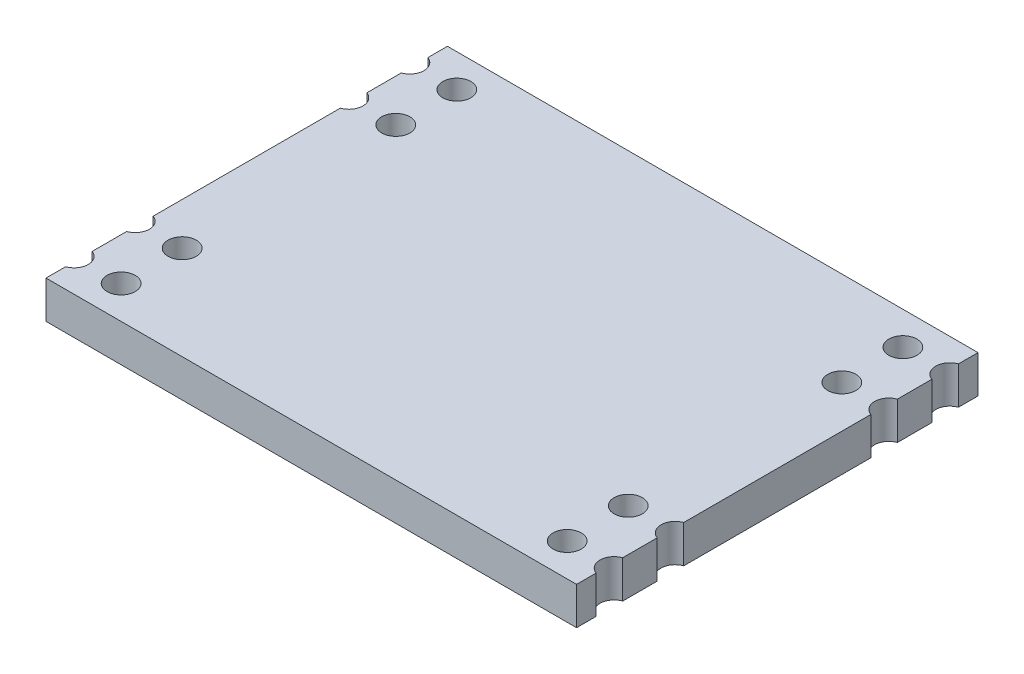
from build123d import *

# Parameters (mm, degrees)
SKETCH1_W                       = 22.6
SKETCH1_H                       = 17.1
MAIN_BODY_DEPTH                 = 1.6
SKETCH2_R                       = 0.6
SOLDERED_CONNECTION_HOLES_DEPTH = 2.6
LPATTERN1_COUNT                 = 2
LPATTERN1_PITCH                 = 2
MIRROR1_COPY_1_SKETCH_R         = 0.6
MIRROR1_COPY_1_DEPTH            = 2.6
MIRROR2_COPY_1_SKETCH_R         = 0.6
MIRROR2_COPY_1_DEPTH            = 2.6
MIRROR2_COPY_2_SKETCH_R         = 0.6
MIRROR2_COPY_2_DEPTH            = 2.6
MIRROR2_COPY_3_SKETCH_R         = 0.6
MIRROR2_COPY_3_DEPTH            = 2.6


with BuildPart() as part:
    # Sketch1 → MAIN BODY (new body)
    with BuildSketch(Plane(origin=(0, 0, 0), x_dir=(1, 0, 0), z_dir=(0, 1, 0))):
        Rectangle(SKETCH1_W, SKETCH1_H)
    extrude(amount=MAIN_BODY_DEPTH)

    # Sketch2 → SOLDERED CONNECTION HOLES (cut, through all)
    with BuildSketch(Plane(origin=(0, 1.6, 0), x_dir=(1, 0, 0), z_dir=(0, 1, 0))):
        with Locations((-9.5, 7.15)):
            Circle(SKETCH2_R)
        with Locations((-9.5, 4.55)):
            Circle(SKETCH2_R)
    soldered_connection_holes = extrude(amount=-SOLDERED_CONNECTION_HOLES_DEPTH, mode=Mode.SUBTRACT)

    # LPattern1: SOLDERED CONNECTION HOLES ×2
    with Locations(*[(-i * LPATTERN1_PITCH, 0, 0) for i in range(1, LPATTERN1_COUNT)]):
        add(soldered_connection_holes, mode=Mode.SUBTRACT)

    # Mirror1: SOLDERED CONNECTION HOLES across plane
    add(soldered_connection_holes.mirror(Plane(origin=(0, 0, 0), x_dir=(0, 0, 1), z_dir=(1, 0, 0))), mode=Mode.SUBTRACT)

    # Mirror1 copy 1 sketch → Mirror1 copy 1 (cut, through all)
    with BuildSketch(Plane(origin=(2, 1.6, 0), x_dir=(-1, 0, 0), z_dir=(0, 1, 0))):
        with Locations((-9.5, -7.15)):
            Circle(MIRROR1_COPY_1_SKETCH_R)
        with Locations((-9.5, -4.55)):
            Circle(MIRROR1_COPY_1_SKETCH_R)
    extrude(amount=-MIRROR1_COPY_1_DEPTH, mode=Mode.SUBTRACT)

    # Mirror2: SOLDERED CONNECTION HOLES across plane
    add(soldered_connection_holes.mirror(Plane.XY), mode=Mode.SUBTRACT)

    # Mirror2 copy 1 sketch → Mirror2 copy 1 (cut, through all)
    with BuildSketch(Plane(origin=(-2, 1.6, 0), x_dir=(1, 0, 0), z_dir=(0, 1, 0))):
        with Locations((-9.5, -7.15)):
            Circle(MIRROR2_COPY_1_SKETCH_R)
        with Locations((-9.5, -4.55)):
            Circle(MIRROR2_COPY_1_SKETCH_R)
    extrude(amount=-MIRROR2_COPY_1_DEPTH, mode=Mode.SUBTRACT)

    # Mirror2 copy 2 sketch → Mirror2 copy 2 (cut, through all)
    with BuildSketch(Plane(origin=(0, 1.6, 0), x_dir=(-1, 0, 0), z_dir=(0, 1, 0))):
        with Locations((-9.5, 7.15)):
            Circle(MIRROR2_COPY_2_SKETCH_R)
        with Locations((-9.5, 4.55)):
            Circle(MIRROR2_COPY_2_SKETCH_R)
    extrude(amount=-MIRROR2_COPY_2_DEPTH, mode=Mode.SUBTRACT)

    # Mirror2 copy 3 sketch → Mirror2 copy 3 (cut, through all)
    with BuildSketch(Plane(origin=(2, 1.6, 0), x_dir=(-1, 0, 0), z_dir=(0, 1, 0))):
        with Locations((-9.5, 7.15)):
            Circle(MIRROR2_COPY_3_SKETCH_R)
        with Locations((-9.5, 4.55)):
            Circle(MIRROR2_COPY_3_SKETCH_R)
    extrude(amount=-MIRROR2_COPY_3_DEPTH, mode=Mode.SUBTRACT)


solid = part.part
